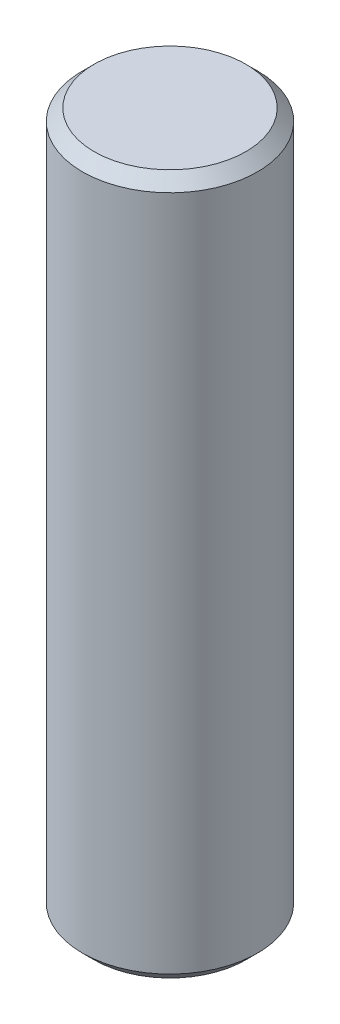
from build123d import *

# Parameters (mm, degrees)
SKETCH_1_R      = 1.5
EXTRUDE_1_DEPTH = 12
CHAMFER_1_SIZE  = 0.2


with BuildPart() as part:
    # 草图1 → 凸台-拉伸1 (new body)
    with BuildSketch(Plane(origin=(0, 0, 0), x_dir=(1, 0, 0), z_dir=(0, 1, 0))):
        Circle(SKETCH_1_R)
    extrude(amount=EXTRUDE_1_DEPTH)

    # 倒角1
    chamfer_1_edges = [part.edges().sort_by_distance(p)[0] for p in [
        (-1.5, 0, 0),
        (-1.5, 12, 0),
    ]]
    chamfer(chamfer_1_edges, length=CHAMFER_1_SIZE)


solid = part.part
